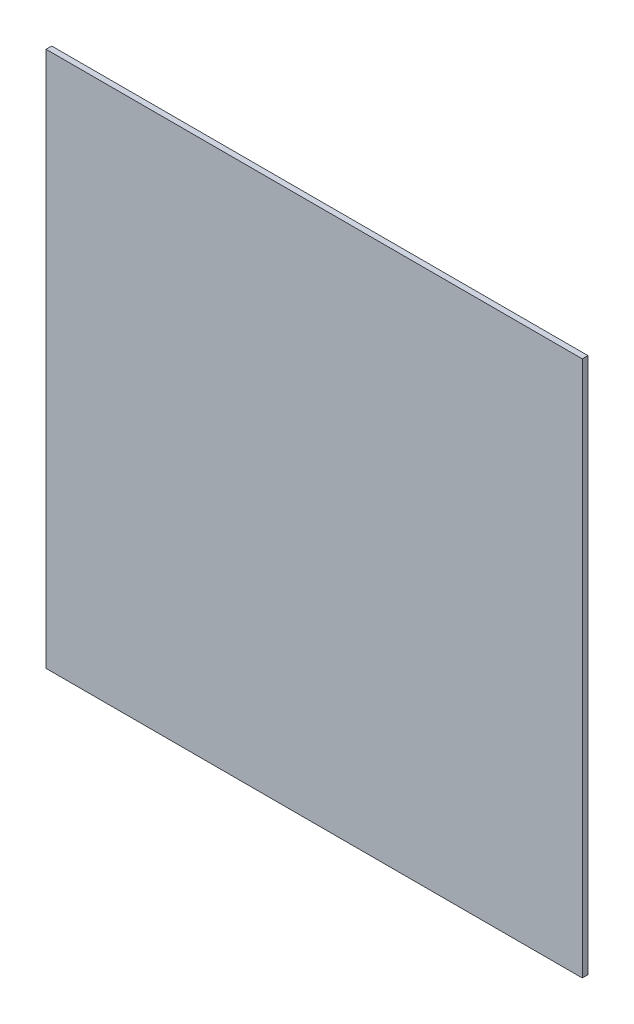
from build123d import *

# Parameters (mm, degrees)
SKETCH1_W           = 300
SKETCH1_H           = 300
BOSS_EXTRUDE1_DEPTH = 3.175


with BuildPart() as part:
    # Sketch1 → Boss-Extrude1 (new body)
    with BuildSketch(Plane.XY):
        Rectangle(SKETCH1_W, SKETCH1_H)
    extrude(amount=BOSS_EXTRUDE1_DEPTH)


solid = part.part
